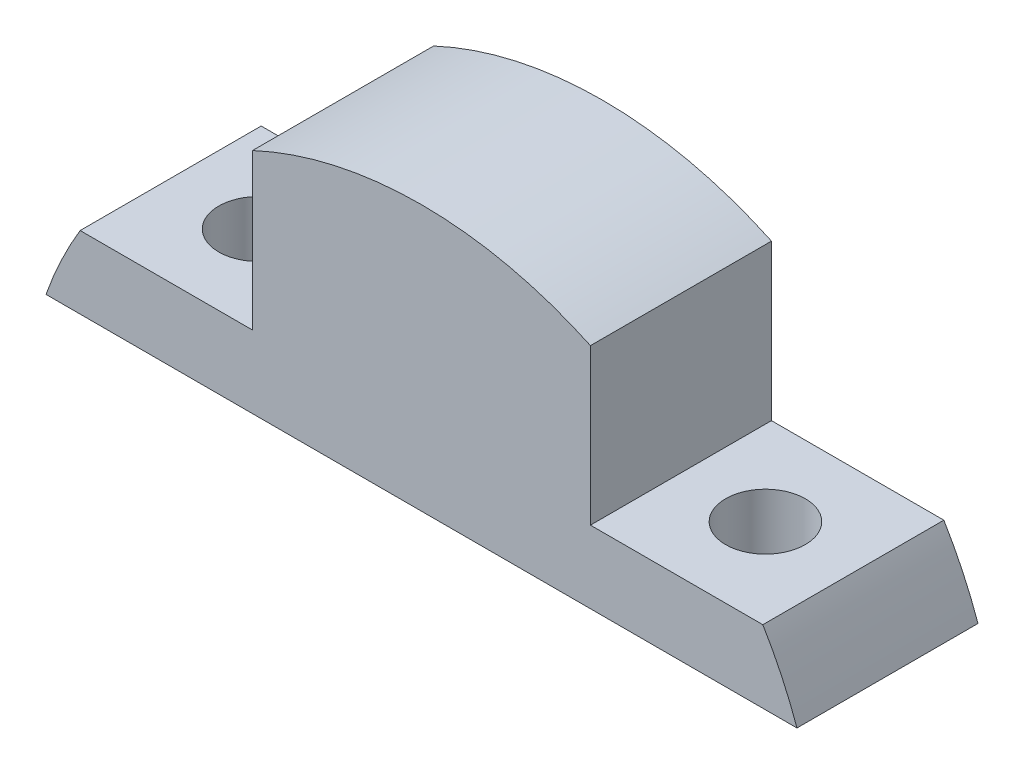
from build123d import *

# Parameters (mm, degrees)
EXTRUDE_1_DEPTH          = 7.5
CUT_EXTRUDE_3_DEPTH      = 8.5
CUT_EXTRUDE_3_DEPTH_BACK = 8.5
HOLE_WIZARD_M4_1_D       = 6.6


with BuildPart() as part:
    # 스케치1 → 보스-돌출1 (new body, symmetric)
    with BuildSketch(Plane.XY):
        Polygon((-14, 22), (14, 22), (14, 6), (40, 6), (40, 0), (-40, 0), (-40, 6), (-14, 6), align=None)
    extrude(amount=EXTRUDE_1_DEPTH, both=True)

    # 스케치2 → 컷-돌출3 (cut, two sides)
    with BuildSketch(Plane.XY) as cut_extrude_3_sk:
        with BuildLine():
            Line((-40, 0), (-31.112698372, 0))
            ThreePointArc((-31.112698372, 0), (0, 22), (31.112698372, 0))
            Line((31.112698372, 0), (40, 0))
            Line((40, 0), (40, 32))
            Line((40, 32), (-40, 32))
            Line((-40, 32), (-40, 0))
        make_face()
    extrude(amount=CUT_EXTRUDE_3_DEPTH, mode=Mode.SUBTRACT)
    extrude(cut_extrude_3_sk.sketch, amount=-CUT_EXTRUDE_3_DEPTH_BACK, mode=Mode.SUBTRACT)

    # M4 여유 구멍1 (through all)
    with Locations(Plane(origin=(0, 6, 0), x_dir=(1, 0, 0), z_dir=(0, 1, 0))):
        with Locations((-21, 0), (21, 0)):
            Hole(HOLE_WIZARD_M4_1_D / 2)


solid = part.part
